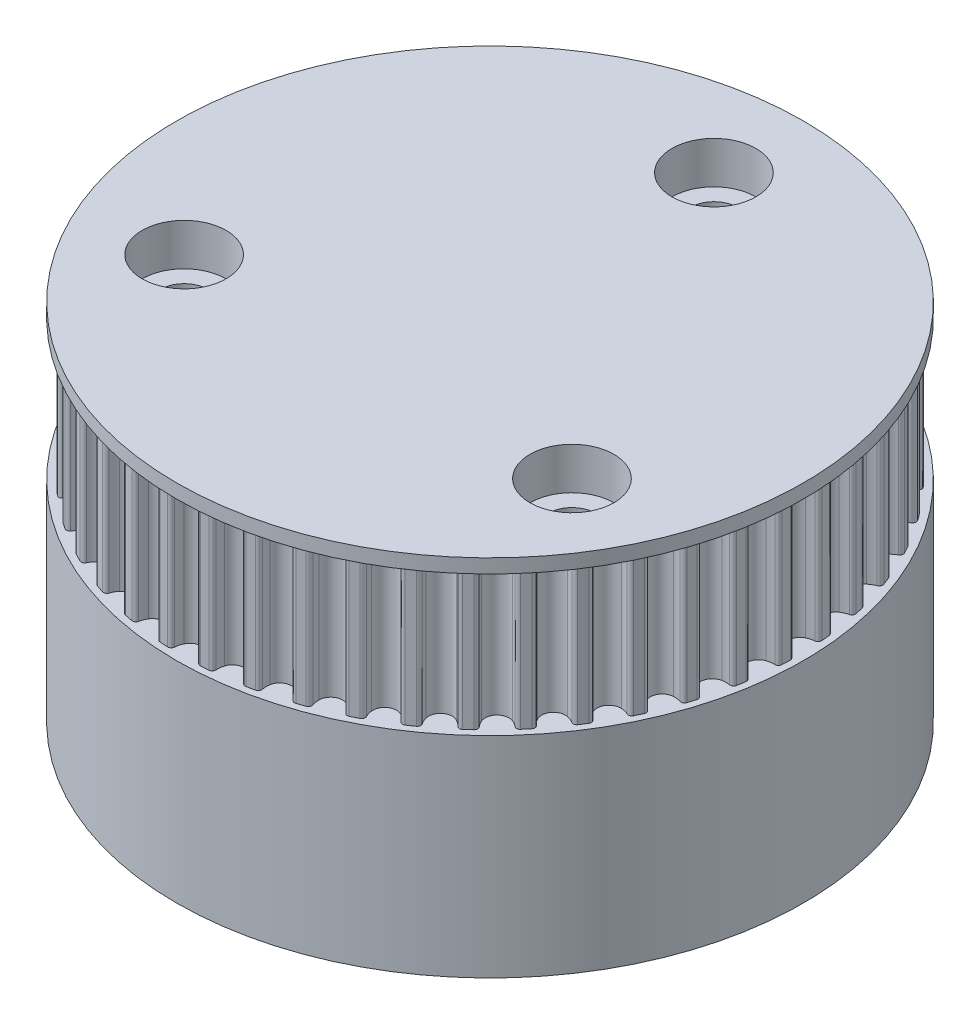
from build123d import *

# Parameters (mm, degrees)
SKETCH2_R                = 21.9
BOSS_EXTRUDE1_DEPTH      = 5
BOSS_EXTRUDE1_DEPTH_BACK = 5
CUT_EXTRUDE1_DEPTH       = 10
SKETCH4_R                = 22.4
BOSS_EXTRUDE2_DEPTH      = 1
SKETCH11_R               = 1.7
CUT_EXTRUDE6_DEPTH       = 13
SKETCH12_R               = 22.4
SKETCH12_R_2             = 1.7
BOSS_EXTRUDE3_DEPTH      = 14
CUT_EXTRUDE7_DEPTH       = 14.5
CHAMFER1_SIZE            = 7
CHAMFER1_SIZE2           = 4.041451884
CHAMFER1_PART_2_SIZE     = 7
CHAMFER1_PART_2_SIZE2    = 4.041451884
CHAMFER1_PART_3_SIZE     = 7
CHAMFER1_PART_3_SIZE2    = 4.041451884
SKETCH14_R               = 3
CUT_EXTRUDE8_DEPTH       = 3


with BuildPart() as part:
    # Sketch2 → Boss-Extrude1 (new body, two sides)
    with BuildSketch(Plane(origin=(0, 0, 0), x_dir=(1, 0, 0), z_dir=(0, 1, 0))) as boss_extrude1_sk:
        Circle(SKETCH2_R)
    extrude(amount=BOSS_EXTRUDE1_DEPTH)
    extrude(boss_extrude1_sk.sketch, amount=-BOSS_EXTRUDE1_DEPTH_BACK)

    # Sketch3 → Cut-Extrude1 (cut)
    with BuildSketch(Plane(origin=(0, 5, 0), x_dir=(1, 0, 0), z_dir=(0, 1, 0))):
        with BuildLine():
            ThreePointArc((0.293226598, 21.898036856), (0.468340384, 21.82313533), (0.539875116, 21.646619442))
            ThreePointArc((0.539875116, 21.646619442), (0.563575012, 21.370355614), (0.637066581, 21.102993729))
            ThreePointArc((0.637066581, 21.102993729), (1.375928255, 20.5539977), (2.181371436, 20.999614683))
            ThreePointArc((2.181371436, 20.999614683), (2.289843128, 21.25479556), (2.350153925, 21.525435534))
            ThreePointArc((2.350153925, 21.525435534), (2.444577653, 21.690841811), (2.628112381, 21.741734644))
            ThreePointArc((2.628112381, 21.741734644), (1.462758679, 21.851094642), (0.293226598, 21.898036856))
        make_face()
        with BuildLine():
            ThreePointArc((3.420270074, 21.381518913), (3.406936142, 21.104561165), (3.44413613, 20.829789353))
            ThreePointArc((3.44413613, 20.829789353), (4.103231293, 20.187211124), (4.960882829, 20.521497015))
            ThreePointArc((4.960882829, 20.521497015), (5.102398963, 20.759943176), (5.198244414, 21.020129719))
            ThreePointArc((5.198244414, 21.020129719), (5.313872144, 21.171474705), (5.502552632, 21.197450661))
            ThreePointArc((5.502552632, 21.197450661), (4.362173074, 21.46116134), (3.209332942, 21.663568083))
            ThreePointArc((3.209332942, 21.663568083), (3.372900877, 21.565994483), (3.420270074, 21.381518913))
        make_face()
        with BuildLine():
            ThreePointArc((6.239630231, 20.734864673), (6.189500416, 20.462155322), (6.189744989, 20.184876892))
            ThreePointArc((6.189744989, 20.184876892), (6.757312071, 19.460183287), (7.65186715, 19.677172746))
            ThreePointArc((7.65186715, 19.677172746), (7.823902367, 19.894629114), (7.953572109, 20.139719192))
            ThreePointArc((7.953572109, 20.139719192), (8.088340462, 20.274302132), (8.278799701, 20.274897669))
            ThreePointArc((8.278799701, 20.274897669), (7.183744387, 20.688253106), (6.068168663, 21.042512423))
            ThreePointArc((6.068168663, 21.042512423), (6.217271873, 20.924007953), (6.239630231, 20.734864673))
        make_face()
        with BuildLine():
            ThreePointArc((8.947644039, 19.718196281), (8.861612909, 19.454601833), (8.824897701, 19.179764824))
            ThreePointArc((8.824897701, 19.179764824), (9.290808456, 18.385888019), (10.20630372, 18.481708864))
            ThreePointArc((10.20630372, 18.481708864), (10.405788049, 18.674294925), (10.566968121, 18.899914898))
            ThreePointArc((10.566968121, 18.899914898), (10.718472151, 19.015334157), (10.907311394, 18.990538648))
            ThreePointArc((10.907311394, 18.990538648), (9.877121611, 19.546162505), (8.81871777, 20.045952631))
            ThreePointArc((8.81871777, 20.045952631), (8.950695505, 19.908632006), (8.947644039, 19.718196281))
        make_face()
        with BuildLine():
            ThreePointArc((11.495986926, 18.349656209), (11.375589709, 18.099880514), (11.302569905, 17.8323894))
            ThreePointArc((11.302569905, 17.8323894), (11.658510143, 16.983496143), (12.578608559, 16.956438449))
            ThreePointArc((12.578608559, 16.956438449), (12.801982196, 17.1207175), (12.991796336, 17.322841175))
            ThreePointArc((12.991796336, 17.322841175), (13.157332452, 17.417037093), (13.341181856, 17.367293015))
            ThreePointArc((13.341181856, 17.367293015), (12.394241366, 18.055270171), (11.41189665, 18.691672339))
            ThreePointArc((11.41189665, 18.691672339), (11.524393764, 18.537986048), (11.495986926, 18.349656209))
        make_face()
        with BuildLine():
            ThreePointArc((13.839183655, 16.653666088), (13.686568841, 16.422166398), (13.578547482, 16.166794563))
            ThreePointArc((13.578547482, 16.166794563), (13.818165441, 15.278033376), (14.72644783, 15.128579988))
            ThreePointArc((14.72644783, 15.128579988), (14.969724667, 15.261620465), (15.184785638, 15.436640941))
            ThreePointArc((15.184785638, 15.436640941), (15.361399843, 15.50793259), (15.536978612, 15.434127627))
            ThreePointArc((15.536978612, 15.434127627), (14.69018559, 16.242181114), (13.801429964, 17.003838712))
            ThreePointArc((13.801429964, 17.003838712), (13.892438943, 16.836529291), (13.839183655, 16.653666088))
        make_face()
        with BuildLine():
            ThreePointArc((15.935419824, 14.660490901), (15.753310829, 14.451398333), (15.612215556, 14.212702895))
            ThreePointArc((15.612215556, 14.212702895), (15.731235249, 13.299933742), (16.611493291, 13.03075166))
            ThreePointArc((16.611493291, 13.03075166), (16.870332048, 13.130179452), (17.10680208, 13.274973484))
            ThreePointArc((17.10680208, 13.274973484), (17.29134269, 13.322088663), (17.455517617, 13.225539866))
            ThreePointArc((17.455517617, 13.225539866), (16.723983104, 14.139249949), (15.944676434, 15.01257118))
            ThreePointArc((15.944676434, 15.01257118), (16.012573221, 14.834624269), (15.935419824, 14.660490901))
        make_face()
        with BuildLine():
            ThreePointArc((17.747288048, 12.405698906), (17.538934611, 12.222744723), (17.367283275, 12.004985207))
            ThreePointArc((17.367283275, 12.004985207), (17.363580791, 11.084496475), (18.20010626, 10.700389259))
            ThreePointArc((18.20010626, 10.700389259), (18.469887953, 10.764430076), (18.723547235, 10.87641381))
            ThreePointArc((18.723547235, 10.87641381), (18.912721117, 10.898511747), (19.062562496, 10.780942032))
            ThreePointArc((19.062562496, 10.780942032), (18.459340744, 11.784003534), (17.803389774, 12.753403959))
            ThreePointArc((17.803389774, 12.753403959), (17.846962749, 12.567995026), (17.747288048, 12.405698906))
        make_face()
        with BuildLine():
            ThreePointArc((19.242455497, 9.929526921), (19.011575689, 9.775975944), (18.812431411, 9.583038274))
            ThreePointArc((18.812431411, 9.583038274), (18.686072823, 8.671256106), (19.463937902, 8.179078158))
            ThreePointArc((19.463937902, 8.179078158), (19.73984827, 8.20658919), (20.006170245, 8.283764274))
            ThreePointArc((20.006170245, 8.283764274), (20.196601588, 8.280450631), (20.329435496, 8.143958032))
            ThreePointArc((20.329435496, 8.143958032), (19.865291011, 9.218471297), (19.344401202, 10.266651943))
            ThreePointArc((19.344401202, 10.266651943), (19.362872805, 10.077089614), (19.242455497, 9.929526921))
        make_face()
        with BuildLine():
            ThreePointArc((20.394240871, 7.276162292), (20.144954749, 7.154754642), (19.921871264, 6.990081795))
            ThreePointArc((19.921871264, 6.990081795), (19.675111442, 6.103276966), (20.380435111, 5.511811214))
            ThreePointArc((20.380435111, 5.511811214), (20.657550527, 5.502301525), (20.931782673, 5.543290769))
            ThreePointArc((20.931782673, 5.543290769), (21.120073225, 5.514624678), (21.233529237, 5.361644909))
            ThreePointArc((21.233529237, 5.361644909), (20.916744689, 6.488435221), (20.540211333, 7.59669128))
            ThreePointArc((20.540211333, 7.59669128), (20.533251937, 7.406358299), (20.394240871, 7.276162292))
        make_face()
        with BuildLine():
            ThreePointArc((21.182090534, 4.492954375), (20.918846615, 4.405856574), (20.675804852, 4.272387141))
            ThreePointArc((20.675804852, 4.272387141), (20.313047232, 3.426384704), (20.933242972, 2.746185868))
            ThreePointArc((20.933242972, 2.746185868), (21.206618305, 2.699825159), (21.483866943, 2.703897108))
            ThreePointArc((21.483866943, 2.703897108), (21.666656655, 2.650390117), (21.758710147, 2.483653104))
            ThreePointArc((21.758710147, 2.483653104), (21.594938562, 3.642612865), (21.369480906, 4.791167481))
            ThreePointArc((21.369480906, 4.791167481), (21.337214701, 4.603460345), (21.182090534, 4.492954375))
        make_face()
        with BuildLine():
            ThreePointArc((21.59194529, 1.629569581), (21.319441167, 1.578335891), (21.060778213, 1.478451638))
            ThreePointArc((21.060778213, 1.478451638), (20.588496213, 0.688348526), (21.112496617, -0.06844523))
            ThreePointArc((21.112496617, -0.06844523), (21.377253478, -0.15082965), (21.652571099, -0.18374766))
            ThreePointArc((21.652571099, -0.18374766), (21.826598083, -0.261140719), (21.895606358, -0.438659548))
            ThreePointArc((21.895606358, -0.438659548), (21.887770246, 0.731787996), (21.817411585, 1.900145184))
            ThreePointArc((21.817411585, 1.900145184), (21.760414364, 1.718413532), (21.59194529, 1.629569581))
        make_face()
        with BuildLine():
            ThreePointArc((21.61649127, -1.262894922), (21.339589786, -1.277350233), (21.069921487, -1.34186687))
            ThreePointArc((21.069921487, -1.34186687), (20.496542991, -2.061971247), (20.91499726, -2.881854921))
            ThreePointArc((20.91499726, -2.881854921), (21.166411056, -2.998792901), (21.434884611, -3.068113447))
            ThreePointArc((21.434884611, -3.068113447), (21.597043352, -3.168011493), (21.641774956, -3.353144311))
            ThreePointArc((21.641774956, -3.353144311), (21.79001415, -2.192095647), (21.876010038, -1.024785248))
            ThreePointArc((21.876010038, -1.024785248), (21.795298917, -1.197298411), (21.61649127, -1.262894922))
        make_face()
        with BuildLine():
            ThreePointArc((21.255290452, -4.132823034), (20.97893292, -4.110242011), (20.703071513, -4.138239732))
            ThreePointArc((20.703071513, -4.138239732), (20.038828474, -4.775495096), (20.344269281, -5.643837843))
            ThreePointArc((20.344269281, -5.643837843), (20.577853527, -5.793242622), (20.834692099, -5.897728677))
            ThreePointArc((20.834692099, -5.897728677), (20.98208887, -6.018349026), (21.001745566, -6.207792134))
            ThreePointArc((21.001745566, -6.207792134), (21.303414736, -5.076861291), (21.544230574, -3.931428363))
            ThreePointArc((21.544230574, -3.931428363), (21.441245844, -4.091644536), (21.255290452, -4.132823034))
        make_face()
        with BuildLine():
            ThreePointArc((20.514788471, -6.929000821), (20.243906499, -6.869786424), (19.966774738, -6.860765608))
            ThreePointArc((19.966774738, -6.860765608), (19.223520587, -7.40380012), (19.410497334, -8.305106345))
            ThreePointArc((19.410497334, -8.305106345), (19.622083714, -8.484311791), (19.862704013, -8.6220988))
            ThreePointArc((19.862704013, -8.6220988), (19.992708516, -8.761288978), (19.98693953, -8.951661759))
            ThreePointArc((19.98693953, -8.951661759), (20.436655382, -7.871030225), (20.827993805, -6.767915046))
            ThreePointArc((20.827993805, -6.767915046), (20.704573231, -6.912975167), (20.514788471, -6.929000821))
        make_face()
        with BuildLine():
            ThreePointArc((19.408199605, -9.601530425), (19.147627087, -9.506739336), (18.874170394, -9.460860959))
            ThreePointArc((18.874170394, -9.460860959), (18.065168521, -9.899984157), (18.130344603, -10.818170027))
            ThreePointArc((18.130344603, -10.818170027), (18.316157353, -11.023978215), (18.536265503, -11.192607364))
            ThreePointArc((18.536265503, -11.192607364), (18.646557804, -11.347883522), (18.615466083, -11.535788768))
            ThreePointArc((18.615466083, -11.535788768), (19.205203428, -10.524740439), (19.740080993, -9.483628125))
            ThreePointArc((19.740080993, -9.483628125), (19.598427019, -9.610943593), (19.408199605, -9.601530425))
        make_face()
        with BuildLine():
            ThreePointArc((17.955270957, -12.102720491), (17.709657816, -11.974044258), (17.444756033, -11.892127022))
            ThreePointArc((17.444756033, -11.892127022), (16.584443094, -12.219502741), (16.526655443, -13.138183209))
            ThreePointArc((16.526655443, -13.138183209), (16.683378729, -13.366921486), (16.879046896, -13.563383585))
            ThreePointArc((16.879046896, -13.563383585), (16.967658827, -13.731974814), (16.911799204, -13.914059353))
            ThreePointArc((16.911799204, -13.914059353), (17.631034163, -12.99063641), (18.299905967, -12.030105635))
            ThreePointArc((18.299905967, -12.030105635), (18.142546412, -12.137404502), (17.955270957, -12.102720491))
        make_face()
        with BuildLine():
            ThreePointArc((16.181930073, -14.387937222), (15.955659281, -14.227672078), (15.704039587, -14.111177797))
            ThreePointArc((15.704039587, -14.111177797), (14.807767888, -14.32096401), (14.628047725, -15.2237452))
            ThreePointArc((14.628047725, -15.2237452), (14.752884817, -15.471331727), (14.920621298, -15.692120905))
            ThreePointArc((14.920621298, -15.692120905), (14.985971576, -15.871018691), (14.906340867, -16.044033219))
            ThreePointArc((14.906340867, -16.044033219), (15.742238677, -15.224714166), (16.533168687, -14.361905625))
            ThreePointArc((16.533168687, -14.361905625), (16.362911634, -14.447273141), (16.181930073, -14.387937222))
        make_face()
        with BuildLine():
            ThreePointArc((14.119822264, -16.416400874), (13.916931629, -16.227406751), (13.683084182, -16.078414269))
            ThreePointArc((13.683084182, -16.078414269), (12.766847713, -16.166867337), (12.468402149, -17.037639098))
            ThreePointArc((12.468402149, -17.037639098), (12.559125326, -17.299655687), (12.695936859, -17.540831955))
            ThreePointArc((12.695936859, -17.540831955), (12.736859307, -17.726843864), (12.634878525, -17.887700933))
            ThreePointArc((12.634878525, -17.887700933), (13.572522568, -17.187106538), (14.471396619, -16.437417069))
            ThreePointArc((14.471396619, -16.437417069), (14.291280311, -16.499329848), (14.119822264, -16.416400874))
        make_face()
        with BuildLine():
            ThreePointArc((11.805745892, -18.151913462), (11.629856002, -17.937562967), (11.417953817, -17.758731058))
            ThreePointArc((11.417953817, -17.758731058), (10.498102837, -17.724272533), (10.086257641, -18.547495922))
            ThreePointArc((10.086257641, -18.547495922), (10.141247946, -18.819266881), (10.244693126, -19.076526444))
            ThreePointArc((10.244693126, -19.076526444), (10.260457482, -19.266333087), (10.137946475, -19.4121622))
            ThreePointArc((10.137946475, -19.4121622), (11.160604473, -18.842794586), (12.151382136, -18.219602416))
            ThreePointArc((12.151382136, -18.219602416), (11.964620752, -18.256955623), (11.805745892, -18.151913462))
        make_face()
        with BuildLine():
            ThreePointArc((9.280995705, -19.563504725), (9.135245319, -19.327622947), (8.949069794, -19.122142871))
            ThreePointArc((8.949069794, -19.122142871), (8.042019068, -18.965387666), (7.524123626, -19.726372242))
            ThreePointArc((7.524123626, -19.726372242), (7.542399757, -20.003047812), (7.610632601, -20.271799866))
            ThreePointArc((7.610632601, -20.271799866), (7.60095755, -20.46201414), (7.460102531, -20.590212972))
            ThreePointArc((7.460102531, -20.590212972), (8.549525126, -20.162232518), (9.614525951, -19.676658526))
            ThreePointArc((9.614525951, -19.676658526), (9.424452252, -19.688785592), (9.280995705, -19.563504725))
        make_face()
        with BuildLine():
            ThreePointArc((6.590625929, -20.625984783), (6.477615968, -20.372781038), (6.32048941, -20.144319591))
            ThreePointArc((6.32048941, -20.144319591), (5.442425279, -19.868065006), (4.827721448, -20.553230982))
            ThreePointArc((4.827721448, -20.553230982), (4.808957264, -20.82987388), (4.840760157, -21.10532254))
            ThreePointArc((4.840760157, -21.10532254), (4.80581835, -21.292550067), (4.64913288, -21.400830906))
            ThreePointArc((4.64913288, -21.400830906), (5.785879301, -21.121874934), (6.906098323, -20.782584198))
            ThreePointArc((6.906098323, -20.782584198), (6.716104179, -20.769268716), (6.590625929, -20.625984783))
        make_face()
        with BuildLine():
            ThreePointArc((3.782646278, -21.320393654), (3.704393405, -21.054386368), (3.579119742, -20.807020451))
            ThreePointArc((3.579119742, -20.807020451), (2.745711281, -20.416196256), (2.045168465, -21.013316828))
            ThreePointArc((2.045168465, -21.013316828), (1.989698816, -21.284990356), (1.984504234, -21.562220233))
            ThreePointArc((1.984504234, -21.562220233), (1.924919209, -21.743119932), (1.755199343, -21.829550505))
            ThreePointArc((1.755199343, -21.829550505), (2.918984323, -21.704596991), (4.074431206, -21.517644164))
            ThreePointArc((4.074431206, -21.517644164), (3.887907067, -21.479123748), (3.782646278, -21.320393654))
        make_face()
        with BuildLine():
            ThreePointArc((0.907165214, -21.634339594), (0.865065855, -21.360275675), (0.773880597, -21.098419538))
            ThreePointArc((0.773880597, -21.098419538), (0, -20.6), (-0.773880597, -21.098419538))
            ThreePointArc((-0.773880597, -21.098419538), (-0.865065855, -21.360275675), (-0.907165214, -21.634339594))
            ThreePointArc((-0.907165214, -21.634339594), (-0.990330162, -21.805683308), (-1.170055768, -21.868721259))
            ThreePointArc((-1.170055768, -21.868721259), (0, -21.9), (1.170055768, -21.868721259))
            ThreePointArc((1.170055768, -21.868721259), (0.990330162, -21.805683308), (0.907165214, -21.634339594))
        make_face()
        with BuildLine():
            ThreePointArc((-1.984504234, -21.562220233), (-1.989698816, -21.284990356), (-2.045168465, -21.013316828))
            ThreePointArc((-2.045168465, -21.013316828), (-2.745711281, -20.416196256), (-3.579119742, -20.807020451))
            ThreePointArc((-3.579119742, -20.807020451), (-3.704393405, -21.054386368), (-3.782646278, -21.320393654))
            ThreePointArc((-3.782646278, -21.320393654), (-3.887907067, -21.479123748), (-4.074431206, -21.517644164))
            ThreePointArc((-4.074431206, -21.517644164), (-2.918984323, -21.704596991), (-1.755199343, -21.829550505))
            ThreePointArc((-1.755199343, -21.829550505), (-1.924919209, -21.743119932), (-1.984504234, -21.562220233))
        make_face()
        with BuildLine():
            ThreePointArc((-4.840760157, -21.10532254), (-4.808957264, -20.82987388), (-4.827721448, -20.553230982))
            ThreePointArc((-4.827721448, -20.553230982), (-5.442425279, -19.868065006), (-6.32048941, -20.144319591))
            ThreePointArc((-6.32048941, -20.144319591), (-6.477615968, -20.372781038), (-6.590625929, -20.625984783))
            ThreePointArc((-6.590625929, -20.625984783), (-6.716104179, -20.769268716), (-6.906098323, -20.782584198))
            ThreePointArc((-6.906098323, -20.782584198), (-5.785879301, -21.121874934), (-4.64913288, -21.400830906))
            ThreePointArc((-4.64913288, -21.400830906), (-4.80581835, -21.292550067), (-4.840760157, -21.10532254))
        make_face()
        with BuildLine():
            ThreePointArc((-7.610632601, -20.271799866), (-7.542399757, -20.003047812), (-7.524123626, -19.726372242))
            ThreePointArc((-7.524123626, -19.726372242), (-8.042019068, -18.965387666), (-8.949069794, -19.122142871))
            ThreePointArc((-8.949069794, -19.122142871), (-9.135245319, -19.327622947), (-9.280995705, -19.563504725))
            ThreePointArc((-9.280995705, -19.563504725), (-9.424452252, -19.688785592), (-9.614525951, -19.676658526))
            ThreePointArc((-9.614525951, -19.676658526), (-8.549525126, -20.162232518), (-7.460102531, -20.590212972))
            ThreePointArc((-7.460102531, -20.590212972), (-7.60095755, -20.46201414), (-7.610632601, -20.271799866))
        make_face()
        with BuildLine():
            ThreePointArc((-10.244693126, -19.076526444), (-10.141247946, -18.819266881), (-10.086257641, -18.547495922))
            ThreePointArc((-10.086257641, -18.547495922), (-10.498102837, -17.724272533), (-11.417953817, -17.758731058))
            ThreePointArc((-11.417953817, -17.758731058), (-11.629856002, -17.937562967), (-11.805745892, -18.151913462))
            ThreePointArc((-11.805745892, -18.151913462), (-11.964620752, -18.256955623), (-12.151382136, -18.219602416))
            ThreePointArc((-12.151382136, -18.219602416), (-11.160604473, -18.842794586), (-10.137946475, -19.4121622))
            ThreePointArc((-10.137946475, -19.4121622), (-10.260457482, -19.266333087), (-10.244693126, -19.076526444))
        make_face()
        with BuildLine():
            ThreePointArc((-12.695936859, -17.540831955), (-12.559125326, -17.299655687), (-12.468402149, -17.037639098))
            ThreePointArc((-12.468402149, -17.037639098), (-12.766847713, -16.166867337), (-13.683084182, -16.078414269))
            ThreePointArc((-13.683084182, -16.078414269), (-13.916931629, -16.227406751), (-14.119822264, -16.416400874))
            ThreePointArc((-14.119822264, -16.416400874), (-14.291280311, -16.499329848), (-14.471396619, -16.437417069))
            ThreePointArc((-14.471396619, -16.437417069), (-13.572522568, -17.187106538), (-12.634878525, -17.887700933))
            ThreePointArc((-12.634878525, -17.887700933), (-12.736859307, -17.726843864), (-12.695936859, -17.540831955))
        make_face()
        with BuildLine():
            ThreePointArc((-14.920621298, -15.692120905), (-14.752884817, -15.471331727), (-14.628047725, -15.2237452))
            ThreePointArc((-14.628047725, -15.2237452), (-14.807767888, -14.32096401), (-15.704039587, -14.111177797))
            ThreePointArc((-15.704039587, -14.111177797), (-15.955659281, -14.227672078), (-16.181930073, -14.387937222))
            ThreePointArc((-16.181930073, -14.387937222), (-16.362911634, -14.447273141), (-16.533168687, -14.361905625))
            ThreePointArc((-16.533168687, -14.361905625), (-15.742238677, -15.224714166), (-14.906340867, -16.044033219))
            ThreePointArc((-14.906340867, -16.044033219), (-14.985971576, -15.871018691), (-14.920621298, -15.692120905))
        make_face()
        with BuildLine():
            ThreePointArc((-16.879046896, -13.563383585), (-16.683378729, -13.366921486), (-16.526655443, -13.138183209))
            ThreePointArc((-16.526655443, -13.138183209), (-16.584443094, -12.219502741), (-17.444756033, -11.892127022))
            ThreePointArc((-17.444756033, -11.892127022), (-17.709657816, -11.974044258), (-17.955270957, -12.102720491))
            ThreePointArc((-17.955270957, -12.102720491), (-18.142546412, -12.137404502), (-18.299905967, -12.030105635))
            ThreePointArc((-18.299905967, -12.030105635), (-17.631034163, -12.99063641), (-16.911799204, -13.914059353))
            ThreePointArc((-16.911799204, -13.914059353), (-16.967658827, -13.731974814), (-16.879046896, -13.563383585))
        make_face()
        with BuildLine():
            ThreePointArc((-18.536265503, -11.192607364), (-18.316157353, -11.023978215), (-18.130344603, -10.818170027))
            ThreePointArc((-18.130344603, -10.818170027), (-18.065168521, -9.899984157), (-18.874170394, -9.460860959))
            ThreePointArc((-18.874170394, -9.460860959), (-19.147627087, -9.506739336), (-19.408199605, -9.601530425))
            ThreePointArc((-19.408199605, -9.601530425), (-19.598427019, -9.610943593), (-19.740080993, -9.483628125))
            ThreePointArc((-19.740080993, -9.483628125), (-19.205203428, -10.524740439), (-18.615466083, -11.535788768))
            ThreePointArc((-18.615466083, -11.535788768), (-18.646557804, -11.347883522), (-18.536265503, -11.192607364))
        make_face()
        with BuildLine():
            ThreePointArc((-19.862704013, -8.6220988), (-19.622083714, -8.484311791), (-19.410497334, -8.305106345))
            ThreePointArc((-19.410497334, -8.305106345), (-19.223520587, -7.40380012), (-19.966774738, -6.860765608))
            ThreePointArc((-19.966774738, -6.860765608), (-20.243906499, -6.869786424), (-20.514788471, -6.929000821))
            ThreePointArc((-20.514788471, -6.929000821), (-20.704573231, -6.912975167), (-20.827993805, -6.767915046))
            ThreePointArc((-20.827993805, -6.767915046), (-20.436655382, -7.871030225), (-19.98693953, -8.951661759))
            ThreePointArc((-19.98693953, -8.951661759), (-19.992708516, -8.761288978), (-19.862704013, -8.6220988))
        make_face()
        with BuildLine():
            ThreePointArc((-20.834692099, -5.897728677), (-20.577853527, -5.793242622), (-20.344269281, -5.643837843))
            ThreePointArc((-20.344269281, -5.643837843), (-20.038828474, -4.775495096), (-20.703071513, -4.138239732))
            ThreePointArc((-20.703071513, -4.138239732), (-20.97893292, -4.110242011), (-21.255290452, -4.132823034))
            ThreePointArc((-21.255290452, -4.132823034), (-21.441245844, -4.091644536), (-21.544230574, -3.931428363))
            ThreePointArc((-21.544230574, -3.931428363), (-21.303414736, -5.076861291), (-21.001745566, -6.207792134))
            ThreePointArc((-21.001745566, -6.207792134), (-20.98208887, -6.018349026), (-20.834692099, -5.897728677))
        make_face()
        with BuildLine():
            ThreePointArc((-21.434884611, -3.068113447), (-21.166411056, -2.998792901), (-20.91499726, -2.881854921))
            ThreePointArc((-20.91499726, -2.881854921), (-20.496542991, -2.061971247), (-21.069921487, -1.34186687))
            ThreePointArc((-21.069921487, -1.34186687), (-21.339589786, -1.277350233), (-21.61649127, -1.262894922))
            ThreePointArc((-21.61649127, -1.262894922), (-21.795298917, -1.197298411), (-21.876010038, -1.024785248))
            ThreePointArc((-21.876010038, -1.024785248), (-21.79001415, -2.192095647), (-21.641774956, -3.353144311))
            ThreePointArc((-21.641774956, -3.353144311), (-21.597043352, -3.168011493), (-21.434884611, -3.068113447))
        make_face()
        with BuildLine():
            ThreePointArc((-21.652571099, -0.18374766), (-21.377253478, -0.15082965), (-21.112496617, -0.06844523))
            ThreePointArc((-21.112496617, -0.06844523), (-20.588496213, 0.688348526), (-21.060778213, 1.478451638))
            ThreePointArc((-21.060778213, 1.478451638), (-21.319441167, 1.578335891), (-21.59194529, 1.629569581))
            ThreePointArc((-21.59194529, 1.629569581), (-21.760414364, 1.718413532), (-21.817411585, 1.900145184))
            ThreePointArc((-21.817411585, 1.900145184), (-21.887770246, 0.731787996), (-21.895606358, -0.438659548))
            ThreePointArc((-21.895606358, -0.438659548), (-21.826598083, -0.261140719), (-21.652571099, -0.18374766))
        make_face()
        with BuildLine():
            ThreePointArc((-21.483866943, 2.703897108), (-21.206618305, 2.699825159), (-20.933242972, 2.746185868))
            ThreePointArc((-20.933242972, 2.746185868), (-20.313047232, 3.426384704), (-20.675804852, 4.272387141))
            ThreePointArc((-20.675804852, 4.272387141), (-20.918846615, 4.405856574), (-21.182090534, 4.492954375))
            ThreePointArc((-21.182090534, 4.492954375), (-21.337214701, 4.603460345), (-21.369480906, 4.791167481))
            ThreePointArc((-21.369480906, 4.791167481), (-21.594938562, 3.642612865), (-21.758710147, 2.483653104))
            ThreePointArc((-21.758710147, 2.483653104), (-21.666656655, 2.650390117), (-21.483866943, 2.703897108))
        make_face()
        with BuildLine():
            ThreePointArc((-20.931782673, 5.543290769), (-20.657550527, 5.502301525), (-20.380435111, 5.511811214))
            ThreePointArc((-20.380435111, 5.511811214), (-19.675111442, 6.103276966), (-19.921871264, 6.990081795))
            ThreePointArc((-19.921871264, 6.990081795), (-20.144954749, 7.154754642), (-20.394240871, 7.276162292))
            ThreePointArc((-20.394240871, 7.276162292), (-20.533251937, 7.406358299), (-20.540211333, 7.59669128))
            ThreePointArc((-20.540211333, 7.59669128), (-20.916744689, 6.488435221), (-21.233529237, 5.361644909))
            ThreePointArc((-21.233529237, 5.361644909), (-21.120073225, 5.514624678), (-20.931782673, 5.543290769))
        make_face()
        with BuildLine():
            ThreePointArc((-20.006170245, 8.283764274), (-19.73984827, 8.20658919), (-19.463937902, 8.179078158))
            ThreePointArc((-19.463937902, 8.179078158), (-18.686072823, 8.671256106), (-18.812431411, 9.583038274))
            ThreePointArc((-18.812431411, 9.583038274), (-19.011575689, 9.775975944), (-19.242455497, 9.929526921))
            ThreePointArc((-19.242455497, 9.929526921), (-19.362872805, 10.077089614), (-19.344401202, 10.266651943))
            ThreePointArc((-19.344401202, 10.266651943), (-19.865291011, 9.218471297), (-20.329435496, 8.143958032))
            ThreePointArc((-20.329435496, 8.143958032), (-20.196601588, 8.280450631), (-20.006170245, 8.283764274))
        make_face()
        with BuildLine():
            ThreePointArc((-18.723547235, 10.87641381), (-18.469887953, 10.764430076), (-18.20010626, 10.700389259))
            ThreePointArc((-18.20010626, 10.700389259), (-17.363580791, 11.084496475), (-17.367283275, 12.004985207))
            ThreePointArc((-17.367283275, 12.004985207), (-17.538934611, 12.222744723), (-17.747288048, 12.405698906))
            ThreePointArc((-17.747288048, 12.405698906), (-17.846962749, 12.567995026), (-17.803389774, 12.753403959))
            ThreePointArc((-17.803389774, 12.753403959), (-18.459340744, 11.784003534), (-19.062562496, 10.780942032))
            ThreePointArc((-19.062562496, 10.780942032), (-18.912721117, 10.898511747), (-18.723547235, 10.87641381))
        make_face()
        with BuildLine():
            ThreePointArc((-17.10680208, 13.274973484), (-16.870332048, 13.130179452), (-16.611493291, 13.03075166))
            ThreePointArc((-16.611493291, 13.03075166), (-15.731235249, 13.299933742), (-15.612215556, 14.212702895))
            ThreePointArc((-15.612215556, 14.212702895), (-15.753310829, 14.451398333), (-15.935419824, 14.660490901))
            ThreePointArc((-15.935419824, 14.660490901), (-16.012573221, 14.834624269), (-15.944676434, 15.01257118))
            ThreePointArc((-15.944676434, 15.01257118), (-16.723983104, 14.139249949), (-17.455517617, 13.225539866))
            ThreePointArc((-17.455517617, 13.225539866), (-17.29134269, 13.322088663), (-17.10680208, 13.274973484))
        make_face()
        with BuildLine():
            ThreePointArc((-15.184785638, 15.436640941), (-14.969724667, 15.261620465), (-14.72644783, 15.128579988))
            ThreePointArc((-14.72644783, 15.128579988), (-13.818165441, 15.278033376), (-13.578547482, 16.166794563))
            ThreePointArc((-13.578547482, 16.166794563), (-13.686568841, 16.422166398), (-13.839183655, 16.653666088))
            ThreePointArc((-13.839183655, 16.653666088), (-13.892438943, 16.836529291), (-13.801429964, 17.003838712))
            ThreePointArc((-13.801429964, 17.003838712), (-14.69018559, 16.242181114), (-15.536978612, 15.434127627))
            ThreePointArc((-15.536978612, 15.434127627), (-15.361399843, 15.50793259), (-15.184785638, 15.436640941))
        make_face()
        with BuildLine():
            ThreePointArc((-12.991796336, 17.322841175), (-12.801982196, 17.1207175), (-12.578608559, 16.956438449))
            ThreePointArc((-12.578608559, 16.956438449), (-11.658510143, 16.983496143), (-11.302569905, 17.8323894))
            ThreePointArc((-11.302569905, 17.8323894), (-11.375589709, 18.099880514), (-11.495986926, 18.349656209))
            ThreePointArc((-11.495986926, 18.349656209), (-11.524393764, 18.537986048), (-11.41189665, 18.691672339))
            ThreePointArc((-11.41189665, 18.691672339), (-12.394241366, 18.055270171), (-13.341181856, 17.367293015))
            ThreePointArc((-13.341181856, 17.367293015), (-13.157332452, 17.417037093), (-12.991796336, 17.322841175))
        make_face()
        with BuildLine():
            ThreePointArc((-10.566968121, 18.899914898), (-10.405788049, 18.674294925), (-10.20630372, 18.481708864))
            ThreePointArc((-10.20630372, 18.481708864), (-9.290808456, 18.385888019), (-8.824897701, 19.179764824))
            ThreePointArc((-8.824897701, 19.179764824), (-8.861612909, 19.454601833), (-8.947644039, 19.718196281))
            ThreePointArc((-8.947644039, 19.718196281), (-8.950695505, 19.908632006), (-8.81871777, 20.045952631))
            ThreePointArc((-8.81871777, 20.045952631), (-9.877121611, 19.546162505), (-10.907311394, 18.990538648))
            ThreePointArc((-10.907311394, 18.990538648), (-10.718472151, 19.015334157), (-10.566968121, 18.899914898))
        make_face()
        with BuildLine():
            ThreePointArc((-7.953572109, 20.139719192), (-7.823902367, 19.894629114), (-7.65186715, 19.677172746))
            ThreePointArc((-7.65186715, 19.677172746), (-6.757312071, 19.460183287), (-6.189744989, 20.184876892))
            ThreePointArc((-6.189744989, 20.184876892), (-6.189500416, 20.462155322), (-6.239630231, 20.734864673))
            ThreePointArc((-6.239630231, 20.734864673), (-6.217271873, 20.924007953), (-6.068168663, 21.042512423))
            ThreePointArc((-6.068168663, 21.042512423), (-7.183744387, 20.688253106), (-8.278799701, 20.274897669))
            ThreePointArc((-8.278799701, 20.274897669), (-8.088340462, 20.274302132), (-7.953572109, 20.139719192))
        make_face()
        with BuildLine():
            ThreePointArc((-5.198244414, 21.020129719), (-5.102398963, 20.759943176), (-4.960882829, 20.521497015))
            ThreePointArc((-4.960882829, 20.521497015), (-4.103231293, 20.187211124), (-3.44413613, 20.829789353))
            ThreePointArc((-3.44413613, 20.829789353), (-3.406936142, 21.104561165), (-3.420270074, 21.381518913))
            ThreePointArc((-3.420270074, 21.381518913), (-3.372900877, 21.565994483), (-3.209332942, 21.663568083))
            ThreePointArc((-3.209332942, 21.663568083), (-4.362173074, 21.46116134), (-5.502552632, 21.197450661))
            ThreePointArc((-5.502552632, 21.197450661), (-5.313872144, 21.171474705), (-5.198244414, 21.020129719))
        make_face()
        with BuildLine():
            ThreePointArc((-2.350153925, 21.525435534), (-2.289843128, 21.25479556), (-2.181371436, 20.999614683))
            ThreePointArc((-2.181371436, 20.999614683), (-1.375928255, 20.5539977), (-0.637066581, 21.102993729))
            ThreePointArc((-0.637066581, 21.102993729), (-0.563575012, 21.370355614), (-0.539875116, 21.646619442))
            ThreePointArc((-0.539875116, 21.646619442), (-0.468340384, 21.82313533), (-0.293226598, 21.898036856))
            ThreePointArc((-0.293226598, 21.898036856), (-1.462758679, 21.851094642), (-2.628112381, 21.741734644))
            ThreePointArc((-2.628112381, 21.741734644), (-2.444577653, 21.690841811), (-2.350153925, 21.525435534))
        make_face()
    extrude(amount=-CUT_EXTRUDE1_DEPTH, mode=Mode.SUBTRACT)

    # Sketch4 → Boss-Extrude2 (add)
    with BuildSketch(Plane.XZ.offset(5)):
        Circle(SKETCH4_R)
    boss_extrude2 = extrude(amount=BOSS_EXTRUDE2_DEPTH)

    # Mirror1: Boss-Extrude2 across plane
    add(boss_extrude2.mirror(Plane.ZX))

    # Sketch11 → Cut-Extrude6 (cut, through all)
    with BuildSketch(Plane(origin=(0, 6, 0), x_dir=(1, 0, 0), z_dir=(0, 1, 0))):
        with Locations((0, 16)):
            Circle(SKETCH11_R)
        with Locations((13.856406461, -8)):
            Circle(SKETCH11_R)
        with Locations((-13.856406461, -8)):
            Circle(SKETCH11_R)
    extrude(amount=-CUT_EXTRUDE6_DEPTH, mode=Mode.SUBTRACT)

    # Sketch12 → Boss-Extrude3 (add)
    with BuildSketch(Plane.XZ.offset(6)):
        Circle(SKETCH12_R)
        with Locations((0, -16)):
            Circle(SKETCH12_R_2, mode=Mode.SUBTRACT)
        with Locations((13.856406461, 8)):
            Circle(SKETCH12_R_2, mode=Mode.SUBTRACT)
        with Locations((-13.856406461, 8)):
            Circle(SKETCH12_R_2, mode=Mode.SUBTRACT)
    extrude(amount=BOSS_EXTRUDE3_DEPTH)

    # Sketch13 → Cut-Extrude7 (cut)
    with BuildSketch(Plane.XZ.offset(20)):
        with BuildLine():
            Line((-16.412495639, 12.93986039), (0, 3.464101615))
            Line((0, 3.464101615), (16.412495639, 12.93986039))
            ThreePointArc((16.412495639, 12.93986039), (0, 20.9), (-16.412495639, 12.93986039))
        make_face()
        with BuildLine():
            Line((3, -20.683568358), (3, -1.732050808))
            Line((3, -1.732050808), (19.412495639, 7.743707967))
            ThreePointArc((19.412495639, 7.743707967), (18.099930939, -10.45), (3, -20.683568358))
        make_face()
        with BuildLine():
            Line((-19.412495639, 7.743707967), (-3, -1.732050808))
            Line((-3, -1.732050808), (-3, -20.683568358))
            ThreePointArc((-3, -20.683568358), (-18.099930939, -10.45), (-19.412495639, 7.743707967))
        make_face()
    extrude(amount=-CUT_EXTRUDE7_DEPTH, mode=Mode.SUBTRACT)

    # Chamfer1
    chamfer1_edges = [part.edges().sort_by_distance(p)[0] for p in [
        (-18.099930939, -5.5, -10.45),
        (-11.206247819, -5.5, 3.00582858),
        (-3, -5.5, -11.207809583),
    ]]
    chamfer1_side = [part.faces().sort_by_distance(p)[0] for p in [
        (-11.461054104, -5.5, -6.617042672),
    ]]
    chamfer(chamfer1_edges, length=CHAMFER1_SIZE, length2=CHAMFER1_SIZE2, reference=chamfer1_side[0])

    # Chamfer1 part 2
    chamfer1_part_2_edges = [part.edges().sort_by_distance(p)[0] for p in [
        (18.099930939, -5.5, -10.45),
        (3, -5.5, -11.207809583),
        (11.206247819, -5.5, 3.00582858),
    ]]
    chamfer1_part_2_side = [part.faces().sort_by_distance(p)[0] for p in [
        (11.461054104, -5.5, -6.617042672),
    ]]
    chamfer(chamfer1_part_2_edges, length=CHAMFER1_PART_2_SIZE, length2=CHAMFER1_PART_2_SIZE2, reference=chamfer1_part_2_side[0])

    # Chamfer1 part 3
    chamfer1_part_3_edges = [part.edges().sort_by_distance(p)[0] for p in [
        (0, -5.5, 20.9),
        (8.206247819, -5.5, 8.201981003),
        (-8.206247819, -5.5, 8.201981003),
    ]]
    chamfer1_part_3_side = [part.faces().sort_by_distance(p)[0] for p in [
        (0, -5.5, 13.234085345),
    ]]
    chamfer(chamfer1_part_3_edges, length=CHAMFER1_PART_3_SIZE, length2=CHAMFER1_PART_3_SIZE2, reference=chamfer1_part_3_side[0])

    # Sketch14 → Cut-Extrude8 (cut)
    with BuildSketch(Plane(origin=(0, 6, 0), x_dir=(1, 0, 0), z_dir=(0, 1, 0))):
        with Locations((-13.856406461, -8)):
            Circle(SKETCH14_R)
        with Locations((0, 16)):
            Circle(SKETCH14_R)
        with Locations((13.856406461, -8)):
            Circle(SKETCH14_R)
    extrude(amount=-CUT_EXTRUDE8_DEPTH, mode=Mode.SUBTRACT)


solid = part.part
